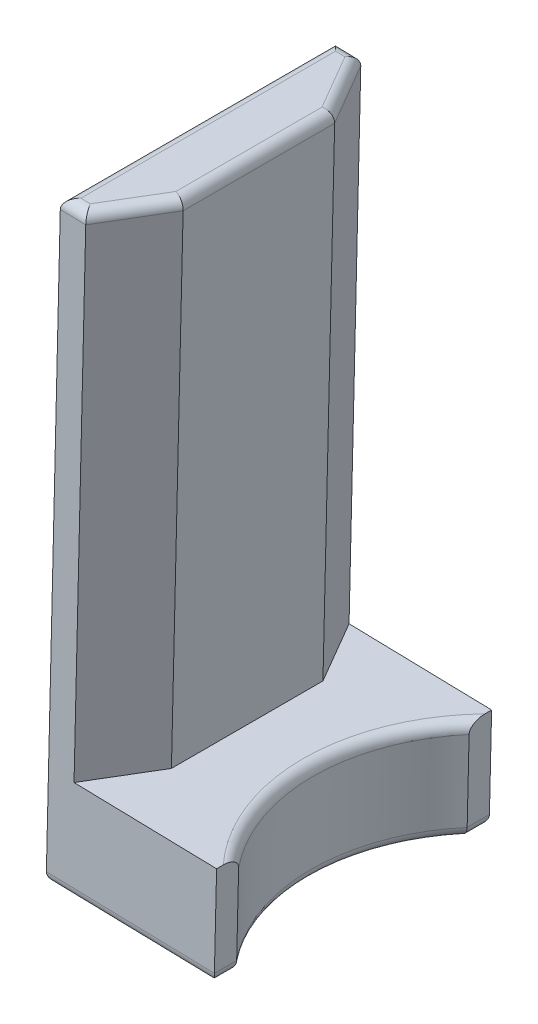
from build123d import *

# Parameters (mm, degrees)
BOSS_EXTRUDE1_DEPTH = 27
SKETCH2_R           = 36
CUT_EXTRUDE1_DEPTH  = 54
CHAMFER1_SIZE       = 7
CHAMFER1_SIZE2      = 12.124355653
CHAMFER2_SIZE       = 7
CHAMFER2_SIZE2      = 12.124355653
FILLET1_R           = 2


with BuildPart() as part:
    # Sketch1 → Boss-Extrude1 (new body, symmetric)
    with BuildSketch(Plane.XY):
        Polygon((302.95878724, 482.984033971), (300.611268609, 385.012154555), (321.60524277, 384.509114849), (321.126157335, 364.514853743), (288.135626511, 365.305344711), (288.614711888, 385.299603421), (290.962230577, 483.271485232), align=None)
    extrude(amount=BOSS_EXTRUDE1_DEPTH, both=True)

    # Sketch2 → Cut-Extrude1 (cut)
    with BuildSketch(Plane(origin=(8.913446831, 371.99582848, 0), x_dir=(0.999713055, -0.023954272, 0), z_dir=(-0.023954272, -0.999713055, 0))):
        with Locations((340.302324012, 0)):
            Circle(SKETCH2_R)
    extrude(amount=-CUT_EXTRUDE1_DEPTH, mode=Mode.SUBTRACT)

    # Chamfer1
    chamfer1_edges = [part.edges().sort_by_distance(p)[0] for p in [
        (301.785027925, 433.998094263, 27),
    ]]
    chamfer1_side = [part.faces().sort_by_distance(p)[0] for p in [
        (299.052126571, 412.848339787, 27),
    ]]
    chamfer(chamfer1_edges, length=CHAMFER1_SIZE, length2=CHAMFER1_SIZE2, reference=chamfer1_side[0])

    # Chamfer2
    chamfer2_edges = [part.edges().sort_by_distance(p)[0] for p in [
        (301.785027925, 433.998094263, -27),
    ]]
    chamfer2_side = [part.faces().sort_by_distance(p)[0] for p in [
        (299.052126571, 412.848339787, -27),
    ]]
    chamfer(chamfer2_edges, length=CHAMFER2_SIZE, length2=CHAMFER2_SIZE2, reference=chamfer2_side[0])

    # Fillet1
    fillet1_edges = [part.edges().sort_by_distance(p)[0] for p in [
        (321.126157335, 364.514853743, -24.813708499),
        (288.135626511, 365.305344711, 0),
        (290.962230577, 483.271485232, 0),
        (304.630891923, 364.910099227, -27),
        (321.126157335, 364.514853743, 24.813708499),
        (313.128452892, 364.706487917, 0),
        (313.607538327, 384.700749023, 0),
        (299.459791547, 483.067873922, 20.937822174),
        (302.95878724, 482.984033971, 0),
        (299.459791547, 483.067873922, -20.937822174),
        (304.630891923, 364.910099227, 27),
        (293.461513215, 483.211599553, -27),
        (293.461513215, 483.211599553, 27),
    ]]
    fillet(fillet1_edges, radius=FILLET1_R)


solid = part.part
